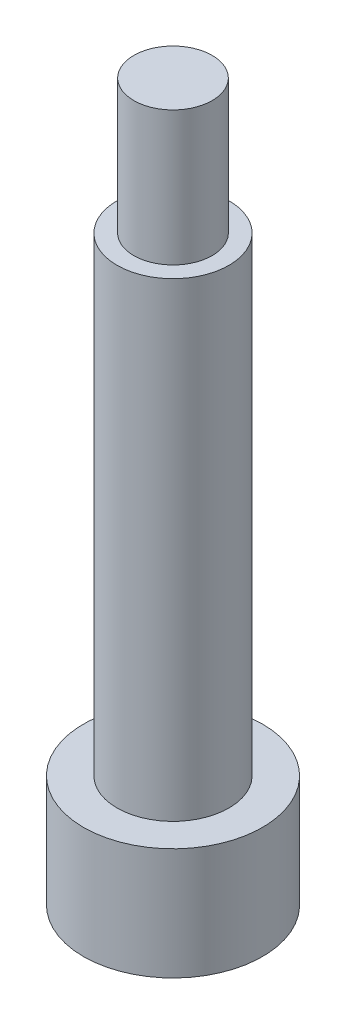
from build123d import *

# Parameters (mm, degrees)
SKETCH_1_R          = 8
EXTRUDE_1_DEPTH     = 10
SKETCH_2_R          = 5
EXTRUDE_2_DEPTH     = 42
SKETCH_3_R          = 3.5
EXTRUDE_3_DEPTH     = 12
CUT_EXTRUDE_1_DEPTH = 10


with BuildPart() as part:
    # Эскиз1 → Бобышка-Вытянуть1 (new body)
    with BuildSketch(Plane(origin=(0, 0, 0), x_dir=(1, 0, 0), z_dir=(0, 1, 0))):
        Circle(SKETCH_1_R)
    extrude(amount=EXTRUDE_1_DEPTH)

    # Эскиз2 → Бобышка-Вытянуть2 (add)
    with BuildSketch(Plane(origin=(0, 10, 0), x_dir=(1, 0, 0), z_dir=(0, 1, 0))):
        Circle(SKETCH_2_R)
    extrude(amount=EXTRUDE_2_DEPTH)

    # Эскиз3 → Бобышка-Вытянуть3 (add)
    with BuildSketch(Plane(origin=(0, 52, 0), x_dir=(1, 0, 0), z_dir=(0, 1, 0))):
        Circle(SKETCH_3_R)
    extrude(amount=EXTRUDE_3_DEPTH)

    # Эскиз4 → Вырез-Вытянуть1 (cut)
    with BuildSketch(Plane(origin=(0, 0, 0), x_dir=(0, 0, -1), z_dir=(1, 0, 0))):
        with BuildLine():
            Line((-2, 42), (-2, 48))
            ThreePointArc((-2, 48), (0, 50), (2, 48))
            Line((2, 48), (2, 42))
            ThreePointArc((2, 42), (0, 40), (-2, 42))
        make_face()
    extrude(amount=-CUT_EXTRUDE_1_DEPTH, mode=Mode.SUBTRACT)


solid = part.part
